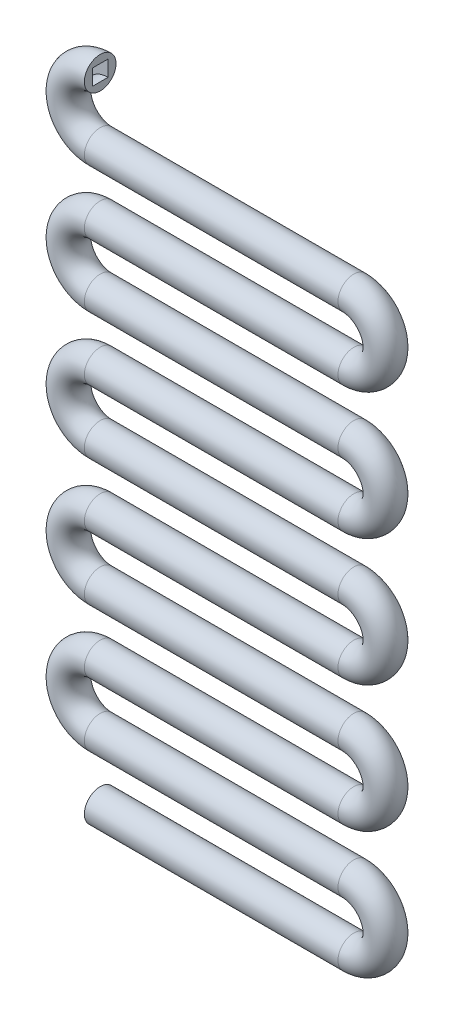
from build123d import *

# Parameters (mm, degrees)
ESBO_O65_R = 5
ESBO_O65_W = 5
ESBO_O65_H = 5


with BuildPart() as part:
    # Varredura5: sweep along a path in Esboço10
    with BuildLine(Plane.XY) as varredura5_path:
        Line((-80, 0), (0, 0))
        ThreePointArc((0, 0), (10, 10), (0, 20))
        Line((0, 20), (-80, 20))
        ThreePointArc((-80, 20), (-90, 30), (-80, 40))
        Line((-80, 40), (0, 40))
        ThreePointArc((0, 40), (10, 50), (0, 60))
        Line((0, 60), (-80, 60))
        ThreePointArc((-80, 60), (-90, 70), (-80, 80))
        Line((-80, 80), (0, 80))
        ThreePointArc((0, 80), (10, 90), (0, 100))
        Line((0, 100), (-80, 100))
        ThreePointArc((-80, 100), (-90, 110), (-80, 120))
        Line((-80, 120), (0, 120))
        ThreePointArc((0, 120), (10, 130), (0, 140))
        Line((0, 140), (-80, 140))
        ThreePointArc((-80, 140), (-90, 150), (-80, 160))
        Line((-80, 160), (0, 160))
        ThreePointArc((0, 160), (10, 170), (0, 180))
        Line((0, 180), (-80, 180))
        ThreePointArc((-80, 180), (-90, 190), (-80, 200))
    # Esboço65 → Varredura5 (sweep)
    with BuildSketch(Plane(origin=(-80, 0, 0), x_dir=(0, 0, -1), z_dir=(1, 0, 0))):
        Circle(ESBO_O65_R)
        Rectangle(ESBO_O65_W, ESBO_O65_H, mode=Mode.SUBTRACT)
    sweep(path=varredura5_path.line)


solid = part.part
